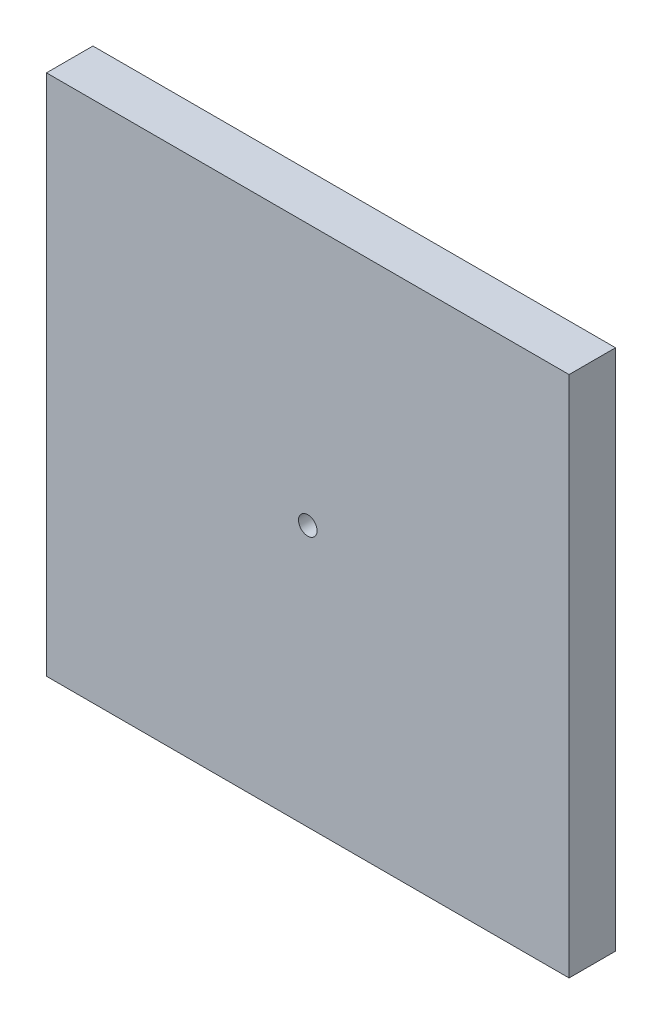
from build123d import *

# Parameters (mm, degrees)
SKETCH1_W           = 45
SKETCH1_H           = 45
SKETCH1_R           = 0.8
BOSS_EXTRUDE1_DEPTH = 4


with BuildPart() as part:
    # Sketch1 → Boss-Extrude1 (new body)
    with BuildSketch(Plane.XY):
        with Locations((22.5, 22.5)):
            Rectangle(SKETCH1_W, SKETCH1_H)
        with Locations((22.5, 22.5)):
            Circle(SKETCH1_R, mode=Mode.SUBTRACT)
    extrude(amount=BOSS_EXTRUDE1_DEPTH)


solid = part.part
